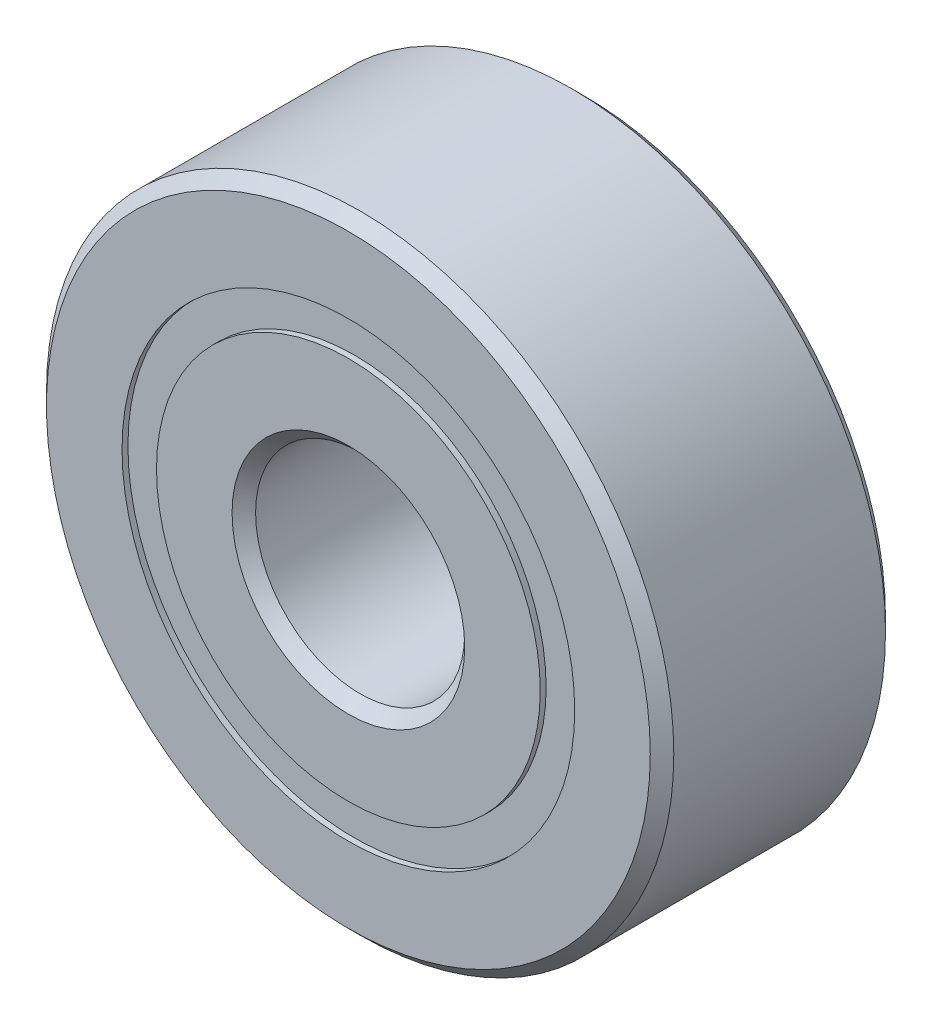
from build123d import *

# Parameters (mm, degrees)
CIRPATTERN1_COUNT = 8
SKETCH5_W         = 1.721739088
SKETCH5_H         = 1.046703296


with BuildPart() as part:
    # Sketch1 → Revolve1 (revolve)
    with BuildSketch(Plane(origin=(0, 0, 0), x_dir=(0, 0, -1), z_dir=(1, 0, 0))):
        with BuildLine():
            Line((3.2146875, 9.525), (-3.2146875, 9.525))
            Line((-3.2146875, 9.525), (-3.571875, 9.1678125))
            Line((-3.571875, 9.1678125), (-3.571875, 6.873351648))
            Line((-3.571875, 6.873351648), (-1.5875, 6.873351648))
            ThreePointArc((-1.5875, 6.873351648), (0, 8.021542162), (1.5875, 6.873351648))
            Line((1.5875, 6.873351648), (3.571875, 6.873351648))
            Line((3.571875, 6.873351648), (3.571875, 9.1678125))
            Line((3.571875, 9.1678125), (3.2146875, 9.525))
        make_face()
    revolve(axis=Axis((0, 0, 3.571875), (0, 0, -1)))


with BuildPart() as body_2:
    # Sketch3 → Revolve3 (revolve)
    with BuildSketch(Plane(origin=(0, 0, 0), x_dir=(0, 0, -1), z_dir=(1, 0, 0))):
        with BuildLine():
            Line((-3.571875, 5.826648352), (-1.5875, 5.826648352))
            ThreePointArc((-1.5875, 5.826648352), (0, 4.678457838), (1.5875, 5.826648352))
            Line((1.5875, 5.826648352), (3.571875, 5.826648352))
            Line((3.571875, 5.826648352), (3.571875, 3.5321875))
            Line((3.571875, 3.5321875), (3.2146875, 3.175))
            Line((3.2146875, 3.175), (-3.2146875, 3.175))
            Line((-3.2146875, 3.175), (-3.571875, 3.5321875))
            Line((-3.571875, 3.5321875), (-3.571875, 5.826648352))
        make_face()
    revolve(axis=Axis((0, 0, 3.571875), (0, 0, -1)))


with BuildPart() as body_3:
    # Sketch4 → Revolve4 (revolve)
    with BuildSketch(Plane(origin=(0, 0, 0), x_dir=(0, 0, -1), z_dir=(1, 0, 0))):
        with BuildLine():
            Line((-1.671542162, 6.35), (1.671542162, 6.35))
            ThreePointArc((1.671542162, 6.35), (0, 8.021542162), (-1.671542162, 6.35))
        make_face()
    revolve(axis=Axis((0, 6.35, 1.671542162), (0, 0, -1)))


with BuildPart() as cirpattern1_1:
    # CirPattern1: pattern copy
    add(body_3.part.rotate(Axis((0, 0, -3.571875), (0, 0, 1)), 1 * 360 / CIRPATTERN1_COUNT))


with BuildPart() as cirpattern1_2:
    # CirPattern1: pattern copy
    add(body_3.part.rotate(Axis((0, 0, -3.571875), (0, 0, 1)), 2 * 360 / CIRPATTERN1_COUNT))


with BuildPart() as cirpattern1_3:
    # CirPattern1: pattern copy
    add(body_3.part.rotate(Axis((0, 0, -3.571875), (0, 0, 1)), 3 * 360 / CIRPATTERN1_COUNT))


with BuildPart() as cirpattern1_4:
    # CirPattern1: pattern copy
    add(body_3.part.rotate(Axis((0, 0, -3.571875), (0, 0, 1)), 4 * 360 / CIRPATTERN1_COUNT))


with BuildPart() as cirpattern1_5:
    # CirPattern1: pattern copy
    add(body_3.part.rotate(Axis((0, 0, -3.571875), (0, 0, 1)), 5 * 360 / CIRPATTERN1_COUNT))


with BuildPart() as cirpattern1_6:
    # CirPattern1: pattern copy
    add(body_3.part.rotate(Axis((0, 0, -3.571875), (0, 0, 1)), 6 * 360 / CIRPATTERN1_COUNT))


with BuildPart() as cirpattern1_7:
    # CirPattern1: pattern copy
    add(body_3.part.rotate(Axis((0, 0, -3.571875), (0, 0, 1)), 7 * 360 / CIRPATTERN1_COUNT))


with BuildPart() as body_11:
    # Sketch5 → Revolve5 (revolve)
    with BuildSketch(Plane(origin=(0, 0, 0), x_dir=(0, 0, -1), z_dir=(1, 0, 0))):
        with Locations((-2.532411706, 6.35)):
            Rectangle(SKETCH5_W, SKETCH5_H)
        with Locations((2.532411706, 6.35)):
            Rectangle(SKETCH5_W, SKETCH5_H)
    revolve(axis=Axis((0, 0, 3.571875), (0, 0, -1)))


solid = Compound([part.part, body_2.part, body_3.part, cirpattern1_1.part, cirpattern1_2.part, cirpattern1_3.part, cirpattern1_4.part, cirpattern1_5.part, cirpattern1_6.part, cirpattern1_7.part, body_11.part])
